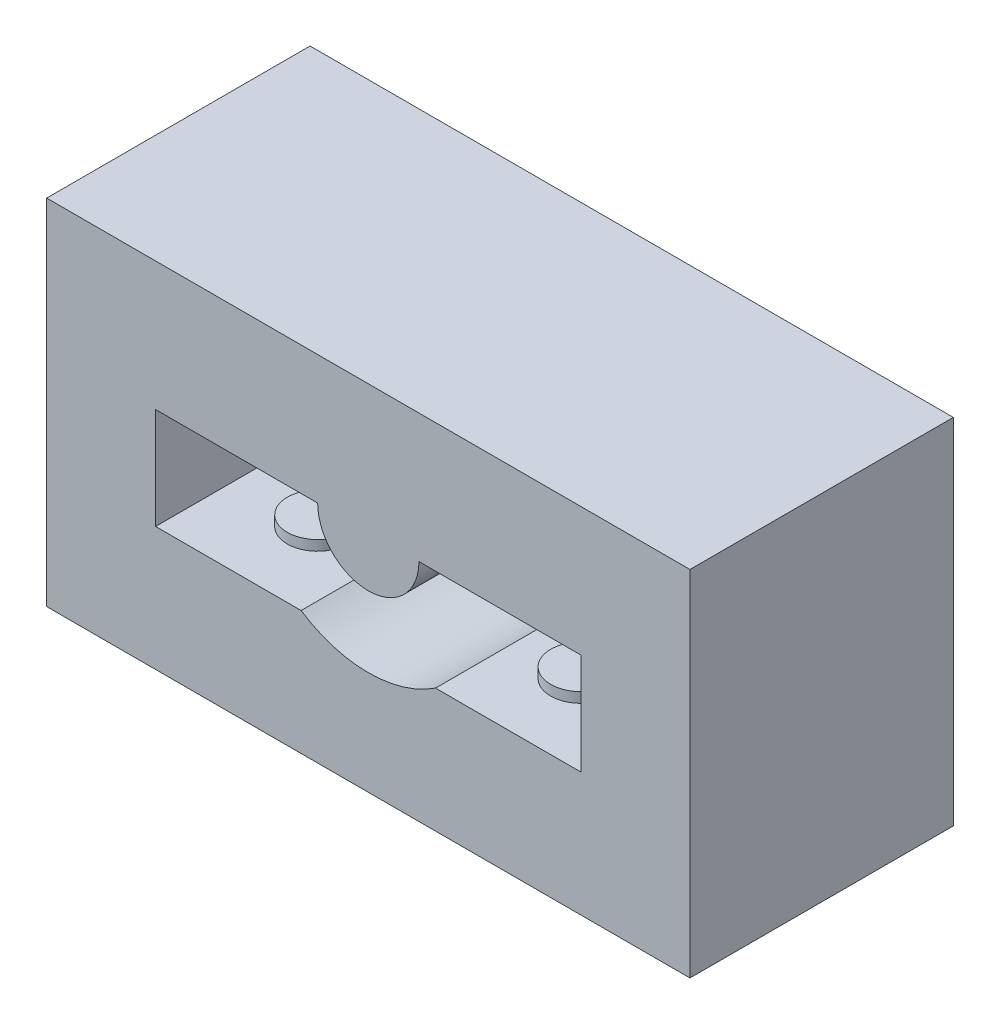
from build123d import *

# Parameters (mm, degrees)
SKETCH1_R      = 24
EXTRUDE1_DEPTH = 5
SKETCH2_R      = 24
EXTRUDE2_DEPTH = 8
SKETCH9_R      = 24
SKETCH9_W      = 31.75
SKETCH9_H      = 17.4625
EXTRUDE4_DEPTH = 13
SKETCH11_R     = 1.5
EXTRUDE6_DEPTH = 0.5


with BuildPart() as part:
    # Sketch1 → Extrude1 (new body)
    with BuildSketch(Plane.XY):
        Circle(SKETCH1_R)
    extrude(amount=EXTRUDE1_DEPTH)

    # Sketch2 → Extrude2 (add)
    with BuildSketch(Plane.XY.offset(5)):
        Circle(SKETCH2_R)
        with BuildLine():
            Line((-2.5, 0), (-10.5, 0))
            Line((-10.5, 0), (-10.5, -5))
            Line((-10.5, -5), (-3.31662479, -5))
            ThreePointArc((-3.31662479, -5), (0, -6), (3.31662479, -5))
            Line((3.31662479, -5), (10.5, -5))
            Line((10.5, -5), (10.5, 0))
            Line((10.5, 0), (2.5, 0))
            ThreePointArc((2.5, 0), (0, -2.5), (-2.5, 0))
        make_face(mode=Mode.SUBTRACT)
    extrude(amount=EXTRUDE2_DEPTH)

    # Sketch9 → Extrude4 (cut)
    with BuildSketch(Plane.XY.offset(13)):
        Circle(SKETCH9_R)
        with Locations((0, -2.38125)):
            Rectangle(SKETCH9_W, SKETCH9_H, mode=Mode.SUBTRACT)
    extrude(amount=-EXTRUDE4_DEPTH, mode=Mode.SUBTRACT)

    # Sketch11 → Extrude6 (add)
    with BuildSketch(Plane(origin=(0, -5, 0), x_dir=(1, 0, 0), z_dir=(0, 1, 0))):
        with Locations((-6.5, -9)):
            Circle(SKETCH11_R)
        with Locations((6.5, -9)):
            Circle(SKETCH11_R)
    extrude(amount=EXTRUDE6_DEPTH)


solid = part.part
